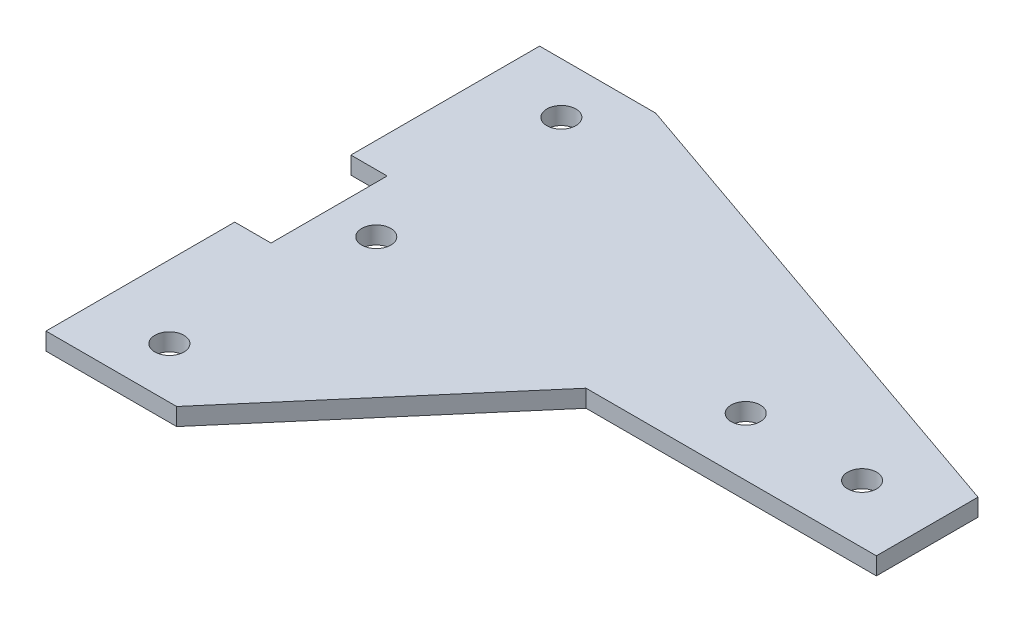
from build123d import *

# Parameters (mm, degrees)
SKETCH1_R           = 2.54
BOSS_EXTRUDE1_DEPTH = 3.048


with BuildPart() as part:
    # Sketch1 → Boss-Extrude1 (new body)
    with BuildSketch(Plane(origin=(0, 0, 0), x_dir=(1, 0, 0), z_dir=(0, 1, 0))):
        Polygon((0, 20.32), (0, 0), (-6.35, 0), (-6.35, -33.02), (16.51, -33.02), (49.550989027, 5.566695169), (100.350989027, 5.566695169), (100.350989027, 23.346695169), (13.97, 53.34), (-6.35, 53.34), (-6.35, 20.32), align=None)
        with Locations((8.255, 10.16)):
            Circle(SKETCH1_R, mode=Mode.SUBTRACT)
        with Locations((87.689183737, 15.726695169)):
            Circle(SKETCH1_R, mode=Mode.SUBTRACT)
        with Locations((6.35, -24.13)):
            Circle(SKETCH1_R, mode=Mode.SUBTRACT)
        with Locations((6.35, 44.45)):
            Circle(SKETCH1_R, mode=Mode.SUBTRACT)
        with Locations((67.330989027, 15.726695169)):
            Circle(SKETCH1_R, mode=Mode.SUBTRACT)
    extrude(amount=BOSS_EXTRUDE1_DEPTH)


solid = part.part
